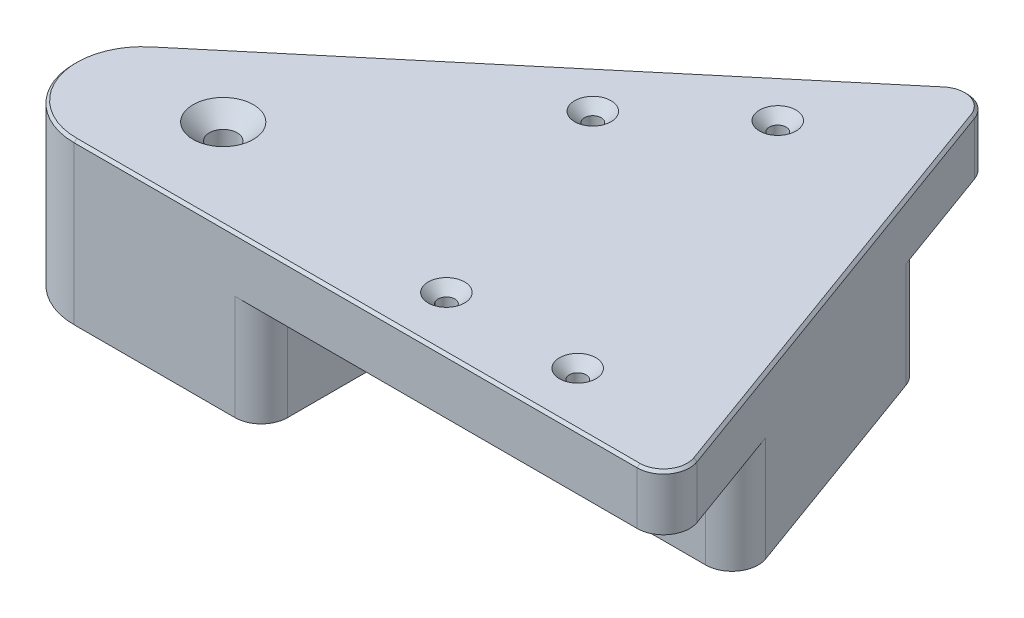
from build123d import *

# Parameters (mm, degrees)
SKETCH1_R                                            = 1.0000000000000018
SKETCH1_R_2                                          = 1.0000000000000087
SKETCH1_R_3                                          = 0.9999999999999911
SKETCH1_R_4                                          = 1.000000000000005
SKETCH1_R_5                                          = 0.9999999999999983
MAIN_BODY_DEPTH                                      = 10.5
PROFILE_STOPS_DEPTH                                  = 20
CSK_FOR_M3_HEX_SOCKET_COUNTERSUNK_HEAD_S_D           = 3.2
CSK_FOR_M3_HEX_SOCKET_COUNTERSUNK_HEAD_S_DEPTH       = 30.5
CSK_FOR_M3_HEX_SOCKET_COUNTERSUNK_HEAD_S_CSINK_D     = 6.94
CSK_FOR_M3_HEX_SOCKET_COUNTERSUNK_HEAD_S_CSINK_ANGLE = 90
CSK_FOR_M5_HEX_SOCKET_COUNTERSUNK_HEAD_S_D           = 5.3
CSK_FOR_M5_HEX_SOCKET_COUNTERSUNK_HEAD_S_DEPTH       = 30.5
CSK_FOR_M5_HEX_SOCKET_COUNTERSUNK_HEAD_S_CSINK_D     = 11.47
CSK_FOR_M5_HEX_SOCKET_COUNTERSUNK_HEAD_S_CSINK_ANGLE = 90
FILLET1_R                                            = 5
FILLET3_R                                            = 5
FILLET4_R                                            = 13
DRAFT1_ANGLE                                         = 0.5000000000000011
CHAMFER1_SIZE                                        = 0.5


with BuildPart() as part:
    # Sketch1 → Main Body (new body)
    with BuildSketch(Plane(origin=(0, 0, 0), x_dir=(1, 0, 0), z_dir=(0, 1, 0))):
        Polygon((-75, 0), (75, 2.755e-14), (39.90666646784656, 96.41814145298106), align=None)
        with Locations(Location((-28.015368960704585, 17.101007166283473, 0), (0, 0, 90))):
            Circle(SKETCH1_R, mode=Mode.SUBTRACT)
        with Locations(Location((21.305293098803567, 10.25, 0), (0, 0, 90))):
            Circle(SKETCH1_R_2, mode=Mode.SUBTRACT)
        with Locations(Location((46.28729909878749, 10.25, 0), (0, 0, 90))):
            Circle(SKETCH1_R_3, mode=Mode.SUBTRACT)
        with Locations(Location((5.362707620569896, 54.05189360917208, 0), (0, 0, 90))):
            Circle(SKETCH1_R_4, mode=Mode.SUBTRACT)
        with Locations(Location((24.500034494822536, 70.11001753107655, 0), (0, 0, 90))):
            Circle(SKETCH1_R_5, mode=Mode.SUBTRACT)
    extrude(amount=MAIN_BODY_DEPTH)

    # Sketch1_3 → Profile Stops (add)
    with BuildSketch(Plane(origin=(0, 0, 0), x_dir=(1, 0, 0), z_dir=(0, 1, 0))):
        Polygon((-75, 0), (-3.676712901180352, 1.84e-15), (-3.67671290118036, 20.5), (67.53861019754284, 20.5), (47.36805627030374, 75.91814145298105), (-7.186046254395704, 30.141814145298103), (-20.363192252969785, 45.84572522923713), align=None)
        Polygon((-41.15292479284825, 23.22715006025093), (-21.889226066737145, 30.238562998427152), (-14.877813128560916, 10.974864272316022), (-34.14151185467204, 3.9634513341398048), align=None, mode=Mode.SUBTRACT)
    extrude(amount=-PROFILE_STOPS_DEPTH)

    # CSK for M3 Hex Socket Countersunk Head S
    with Locations(Plane(origin=(24.500034495, 10.5, -70.110017531), x_dir=(0, 0, 1), z_dir=(0, 1, 0))):
        with Locations((0, 0), (16.058123922, -19.137326874), (59.860017531, 21.787264604), (59.860017531, -3.194741396)):
            CounterSinkHole(CSK_FOR_M3_HEX_SOCKET_COUNTERSUNK_HEAD_S_D / 2, CSK_FOR_M3_HEX_SOCKET_COUNTERSUNK_HEAD_S_CSINK_D / 2, depth=CSK_FOR_M3_HEX_SOCKET_COUNTERSUNK_HEAD_S_DEPTH, counter_sink_angle=CSK_FOR_M3_HEX_SOCKET_COUNTERSUNK_HEAD_S_CSINK_ANGLE)

    # CSK for M5 Hex Socket Countersunk Head S
    with Locations(Plane(origin=(-28.015368961, 10.5, -17.101007166), x_dir=(0, 0, 1), z_dir=(0, 1, 0))):
        with Locations((0, 0)):
            CounterSinkHole(CSK_FOR_M5_HEX_SOCKET_COUNTERSUNK_HEAD_S_D / 2, CSK_FOR_M5_HEX_SOCKET_COUNTERSUNK_HEAD_S_CSINK_D / 2, depth=CSK_FOR_M5_HEX_SOCKET_COUNTERSUNK_HEAD_S_DEPTH, counter_sink_angle=CSK_FOR_M5_HEX_SOCKET_COUNTERSUNK_HEAD_S_CSINK_ANGLE)

    # Fillet1
    fillet1_edges = [part.edges().sort_by_distance(p)[0] for p in [
        (-3.676712901180355, -10, -2.69e-15),
        (-20.363192252969785, -10, -45.84572522923713),
    ]]
    fillet(fillet1_edges, radius=FILLET1_R)

    # Fillet3
    fillet3_edges = [part.edges().sort_by_distance(p)[0] for p in [
        (75, 5.25, -2.755e-14),
        (39.90666646784656, 5.25, -96.41814145298106),
        (47.36805627030374, -10, -75.91814145298105),
        (67.53861019754285, -10, -20.5),
    ]]
    fillet(fillet3_edges, radius=FILLET3_R)

    # Fillet4
    fillet4_edges = [part.edges().sort_by_distance(p)[0] for p in [
        (-75, -4.75, 0),
    ]]
    fillet(fillet4_edges, radius=FILLET4_R)

    # Draft1
    draft1_faces = [part.faces().sort_by_distance(p)[0] for p in [
        (-31.521075429792702, -10, -26.732856529339042),
        (-18.38351959764903, -10, -20.606713635371584),
        (-37.64721832376015, -10, -13.59530069719537),
        (-24.509662491616478, -10, -7.469157803227914),
    ]]
    draft(draft1_faces, Plane(origin=(0, 0, 0), x_dir=(0, 0, -1), z_dir=(0, -1, 0)), DRAFT1_ANGLE)

    # Chamfer1
    chamfer1_edges = [part.edges().sort_by_distance(p)[0] for p in [
        (57.45333323392328, 10.5, -48.209070726490545),
        (38.94457551921066, 10.5, -92.82756915116973),
        (71.9550201877344, 10.5, -2.1321178182447977),
        (14.288233209599724, 10.5, -1.64e-14),
        (-6.601245113874818, 10.5, -57.39336999793299),
        (-51.498797617306785, 10.5, -8.553738136766313),
    ]]
    chamfer(chamfer1_edges, length=CHAMFER1_SIZE)


solid = part.part
